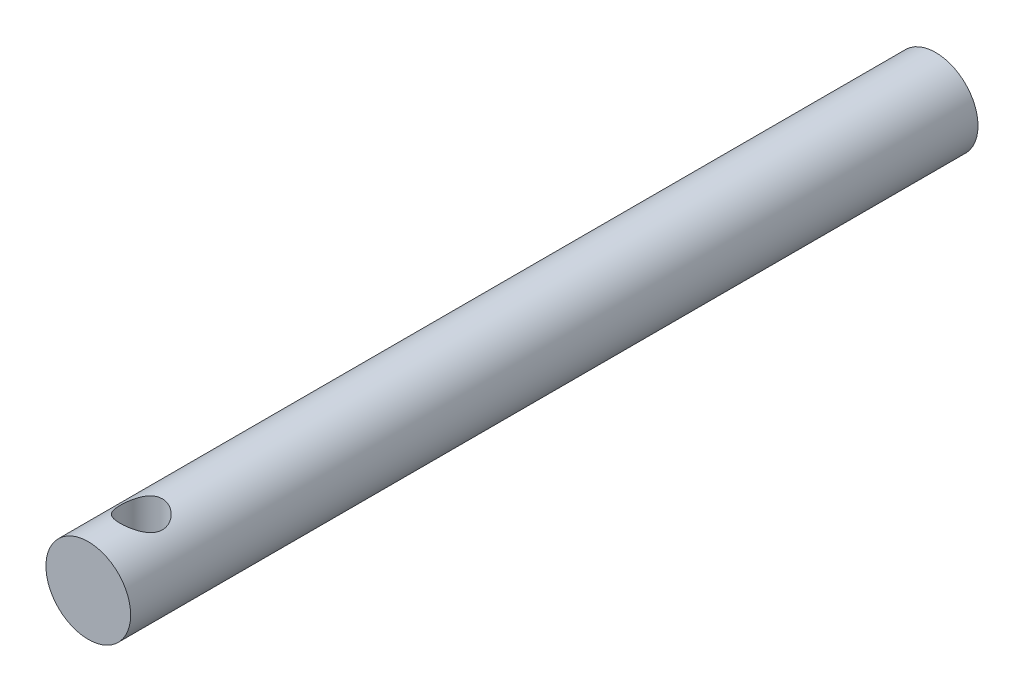
from build123d import *

# Parameters (mm, degrees)
SKETCH_1_R               = 8
EXTRUDE_1_DEPTH          = 160
CUT_EXTRUDE_1_DEPTH      = 120
CUT_EXTRUDE_1_DEPTH_BACK = 120
SKETCH_2_R               = 4
SKETCH_3_R               = 4
CUT_EXTRUDE_2_DEPTH      = 10


with BuildPart() as part:
    # 草图1 → 凸台-拉伸1 (new body)
    with BuildSketch(Plane.XY):
        Circle(SKETCH_1_R)
    extrude(amount=EXTRUDE_1_DEPTH)

    # 草图2 → 切除-拉伸1 (cut, two sides: drawn at the far end of the back side and taken through both)
    with BuildSketch(Plane(origin=(0, 0, 0), x_dir=(1, 0, 0), z_dir=(0, 1, 0)).offset(-CUT_EXTRUDE_1_DEPTH_BACK)):
        with Locations((0, -150)):
            Circle(SKETCH_2_R)
    extrude(amount=CUT_EXTRUDE_1_DEPTH + CUT_EXTRUDE_1_DEPTH_BACK, mode=Mode.SUBTRACT)

    # 草图3 → 切除-拉伸2 (cut)
    with BuildSketch(Plane(origin=(0, 0, 0), x_dir=(-1, 0, 0), z_dir=(0, 0, -1))):
        Circle(SKETCH_3_R)
    extrude(amount=-CUT_EXTRUDE_2_DEPTH, mode=Mode.SUBTRACT)


solid = part.part
